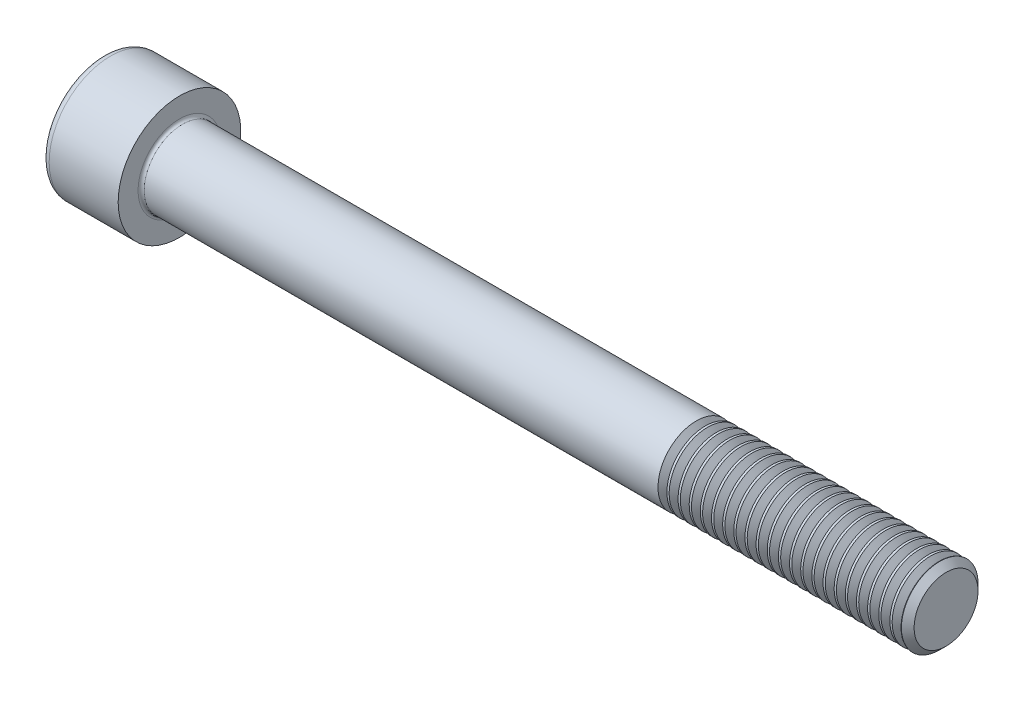
from build123d import *

# Parameters (mm, degrees)
FILLET1_R       = 0.4
FILLET2_R       = 1
HEX_2_DEPTH     = 5
THDSCHPAT_COUNT = 22
THDSCHPAT_PITCH = 1.454545455


with BuildPart() as part:
    # BodySke → Base-Revolve (revolve)
    with BuildSketch(Plane.XY):
        Polygon((0, 0), (0, 8), (10, 8), (10, 5), (109.172, 5), (110, 4.172), (110, 0), align=None)
    revolve(axis=Axis((-31.75, 0, 0), (1, 0, 0)))

    # Fillet1
    fillet1_edges = [part.edges().sort_by_distance(p)[0] for p in [
        (10, -5, 0),
    ]]
    fillet(fillet1_edges, radius=FILLET1_R)

    # Fillet2
    fillet2_edges = [part.edges().sort_by_distance(p)[0] for p in [
        (0, -8, 0),
    ]]
    fillet(fillet2_edges, radius=FILLET2_R)

    # Sketch2 → Hex-PreBroach (revolve, cut)
    with BuildSketch(Plane.XY):
        Polygon((0, 4.0125), (5, 4.0125), (7.316617955, 0), (0, 0), align=None)
    revolve(axis=Axis((0, 0, 0), (1, 0, 0)), mode=Mode.SUBTRACT)

    # Sketch3 → Hex 2 (cut)
    with BuildSketch(Plane(origin=(0, 0, 0), x_dir=(0, 0.5, 0.866025404), z_dir=(-1, 0, 0))):
        Polygon((2.316617955, 4.0125), (-2.316617955, 4.0125), (-4.63323591, 0), (-2.316617955, -4.0125), (2.316617955, -4.0125), (4.63323591, 0), align=None)
    extrude(amount=-HEX_2_DEPTH, mode=Mode.SUBTRACT)

    # ThdSchSke → ThreadSchematic (revolve, cut)
    with BuildSketch(Plane.XY):
        Polygon((78, -4.172), (77.420228158, -5), (77.420228158, -6.25), (78.579771842, -6.25), (78.579771842, -5), align=None)
    threadschematic = revolve(axis=Axis((-3.175, 0, 0), (1, 0, 0)), mode=Mode.SUBTRACT)

    # ThdSchPat: ThreadSchematic ×22
    with Locations(*[(i * THDSCHPAT_PITCH, 0, 0) for i in range(1, THDSCHPAT_COUNT)]):
        add(threadschematic, mode=Mode.SUBTRACT)


solid = part.part
